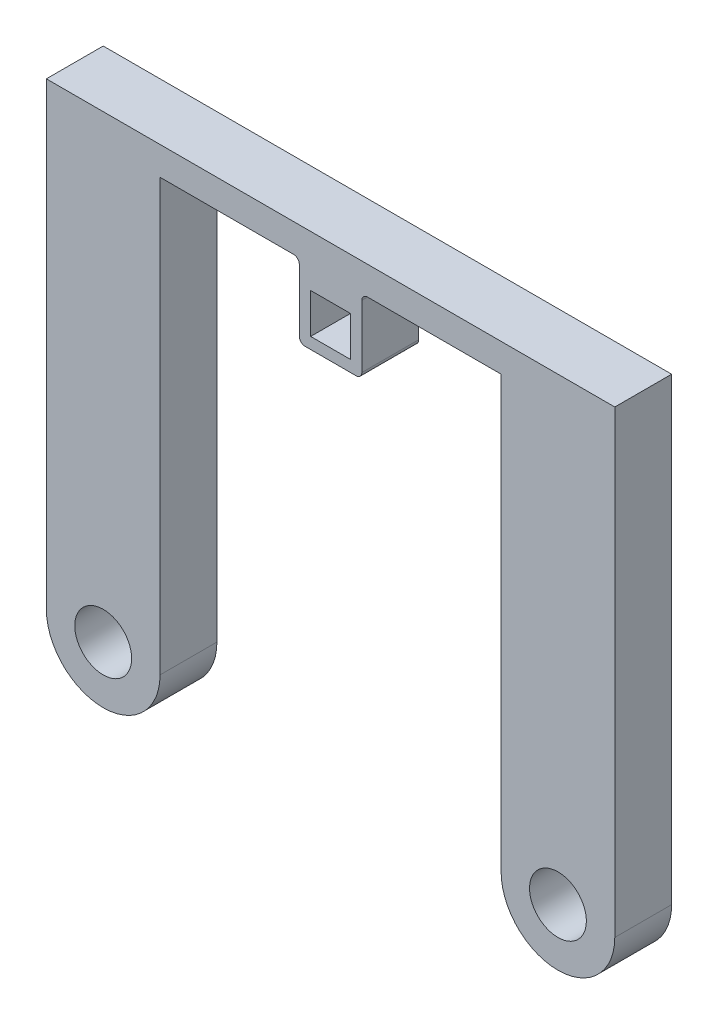
from build123d import *

# Parameters (mm, degrees)
SKETCH1_W           = 60
SKETCH1_H           = 5
SKETCH1_R           = 10
SKETCH1_R_2         = 5
BOSS_EXTRUDE1_DEPTH = 5
SKETCH2_W           = 11
SKETCH2_H           = 13
SKETCH2_W_2         = 7
SKETCH2_H_2         = 7
BOSS_EXTRUDE2_DEPTH = 10
FILLET1_R           = 1


with BuildPart() as part:
    # Sketch1 → Boss-Extrude1 (new body, symmetric)
    with BuildSketch(Plane.XY):
        with BuildLine():
            Line((-50, 80.817230765), (-50, 0))
            ThreePointArc((-50, 0), (-40, 10), (-30, 0))
            Line((-30, 0), (-30, 75.817230765))
            Line((-30, 75.817230765), (-30, 80.817230765))
            Line((-30, 80.817230765), (-50, 80.817230765))
        make_face()
        with Locations((0, 78.317230765)):
            Rectangle(SKETCH1_W, SKETCH1_H)
        with BuildLine():
            Line((50, 80.817230765), (30, 80.817230765))
            Line((30, 80.817230765), (30, 75.817230765))
            Line((30, 75.817230765), (30, 0))
            ThreePointArc((30, 0), (40, 10), (50, 0))
            Line((50, 0), (50, 80.817230765))
        make_face()
        with Locations((-40, 0)):
            Circle(SKETCH1_R)
        with Locations((-40, 0)):
            Circle(SKETCH1_R_2, mode=Mode.SUBTRACT)
        with Locations((40, 0)):
            Circle(SKETCH1_R)
        with Locations((40, 0)):
            Circle(SKETCH1_R_2, mode=Mode.SUBTRACT)
    extrude(amount=BOSS_EXTRUDE1_DEPTH, both=True)

    # Sketch2 → Boss-Extrude2 (add)
    with BuildSketch(Plane.XY.offset(5)):
        with Locations((0, 69.317230765)):
            Rectangle(SKETCH2_W, SKETCH2_H)
        with Locations((0, 68.317230765)):
            Rectangle(SKETCH2_W_2, SKETCH2_H_2, mode=Mode.SUBTRACT)
    extrude(amount=-BOSS_EXTRUDE2_DEPTH)

    # Fillet1
    fillet1_edges = [part.edges().sort_by_distance(p)[0] for p in [
        (5.5, 62.817230765, 0),
        (-5.5, 62.817230765, 0),
        (-5.5, 75.817230765, 0),
        (5.5, 75.817230765, 0),
    ]]
    fillet(fillet1_edges, radius=FILLET1_R)


solid = part.part
